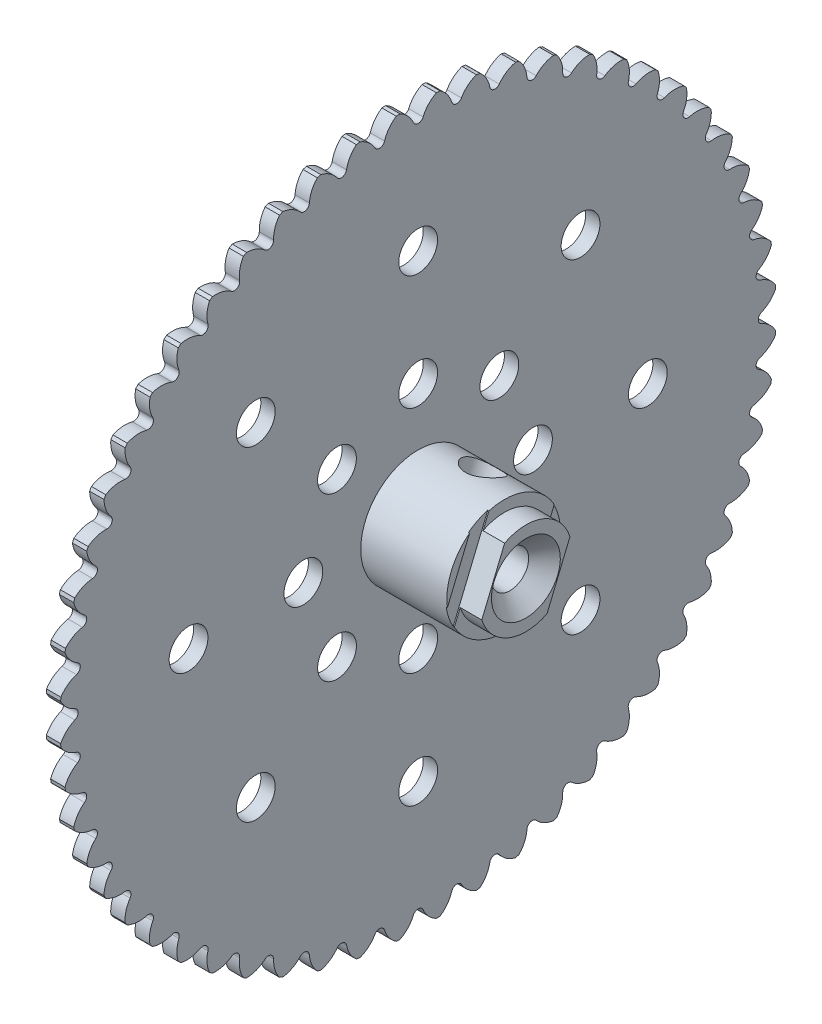
from build123d import *

# Parameters (mm, degrees)
SKETCH1_R           = 39.5986
BOSS_EXTRUDE1_DEPTH = 1.5875
SKETCH2_R           = 2.1463
CUT_EXTRUDE1_DEPTH  = 1.5875
CIRPATTERN1_COUNT   = 8
CUT_EXTRUDE2_DEPTH  = 1.5875
CIRPATTERN2_COUNT   = 56
SKETCH7_R           = 6.35
BOSS_EXTRUDE3_DEPTH = 9.525
BOSS_EXTRUDE4_DEPTH = 2.3876
SKETCH9_R           = 2.0574
CUT_EXTRUDE3_DEPTH  = 14.5001
CUT_EXTRUDE4_DEPTH  = 0.127
SKETCH12_W          = 1.984375
SKETCH12_H          = 12.7


with BuildPart() as part:
    # Sketch1 → Boss-Extrude1 (new body)
    with BuildSketch(Plane(origin=(0, 0, 0), x_dir=(0, 0, -1), z_dir=(1, 0, 0))):
        Circle(SKETCH1_R)
    extrude(amount=BOSS_EXTRUDE1_DEPTH)

    # Sketch2 → Cut-Extrude1 (cut)
    with BuildSketch(Plane(origin=(1.5875, 0, 0), x_dir=(0, 0, -1), z_dir=(1, 0, 0))):
        with Locations((0, 12.7)):
            Circle(SKETCH2_R)
        with Locations((0, 25.4)):
            Circle(SKETCH2_R)
    cut_extrude1 = extrude(amount=-CUT_EXTRUDE1_DEPTH, mode=Mode.SUBTRACT)

    # CirPattern1: Cut-Extrude1 ×8 about axis
    cirpattern1_axis = Axis((0, 0, 0), (1, 0, 0))
    for i in range(1, CIRPATTERN1_COUNT):
        add(cut_extrude1.rotate(cirpattern1_axis, i * 360 / CIRPATTERN1_COUNT), mode=Mode.SUBTRACT)

    # Sketch4 → Cut-Extrude2 (cut)
    with BuildSketch(Plane(origin=(1.5875, 0, 0), x_dir=(0, 0, -1), z_dir=(1, 0, 0))):
        with BuildLine():
            ThreePointArc((2.01740165, 39.547177049), (0, 39.5986), (-2.01740165, 39.547177049))
            ThreePointArc((-2.01740165, 39.547177049), (-1.138604793, 38.888877086), (-0.536592031, 37.970605125))
            ThreePointArc((-0.536592031, 37.970605125), (0, 37.6174), (0.536592031, 37.970605125))
            ThreePointArc((0.536592031, 37.970605125), (1.138604793, 38.888877086), (2.01740165, 39.547177049))
        make_face()
    cut_extrude2 = extrude(amount=-CUT_EXTRUDE2_DEPTH, mode=Mode.SUBTRACT)

    # CirPattern2: Cut-Extrude2 ×56 about axis
    cirpattern2_axis = Axis((0, 0, 0), (1, 0, 0))
    for i in range(1, CIRPATTERN2_COUNT):
        add(cut_extrude2.rotate(cirpattern2_axis, i * 360 / CIRPATTERN2_COUNT), mode=Mode.SUBTRACT)

    # Sketch7 → Boss-Extrude3 (add)
    with BuildSketch(Plane(origin=(1.5875, 0, 0), x_dir=(0, 0, -1), z_dir=(1, 0, 0))):
        Circle(SKETCH7_R)
    extrude(amount=BOSS_EXTRUDE3_DEPTH)

    # Sketch8 → Boss-Extrude4 (add)
    with BuildSketch(Plane(origin=(11.1125, 0, 0), x_dir=(0, 0, -1), z_dir=(1, 0, 0))):
        with BuildLine():
            Line((-4.876953722, -1.552504431), (-2.350740637, 4.546313459))
            ThreePointArc((-2.350740637, 4.546313459), (1.958612075, 4.728507835), (4.876953722, 1.552504431))
            Line((4.876953722, 1.552504431), (2.350740637, -4.546313459))
            ThreePointArc((2.350740637, -4.546313459), (-1.958612075, -4.728507835), (-4.876953722, -1.552504431))
        make_face()
    extrude(amount=BOSS_EXTRUDE4_DEPTH)

    # Sketch9 → Cut-Extrude3 (cut, through all)
    with BuildSketch(Plane(origin=(13.5001, 0, 0), x_dir=(0, 0, -1), z_dir=(1, 0, 0))):
        Circle(SKETCH9_R)
    extrude(amount=-CUT_EXTRUDE3_DEPTH, mode=Mode.SUBTRACT)

    # Sketch10 → Cut-Extrude4 (cut)
    with BuildSketch(Plane(origin=(11.1125, 0, 0), x_dir=(0, 0, -1), z_dir=(1, 0, 0))):
        with BuildLine():
            Line((-5.528101678, -3.124514657), (-1.699592681, 6.118323685))
            ThreePointArc((-1.699592681, 6.118323685), (-2.823102406, 5.687933966), (-3.845267539, 5.053357058))
            Line((-3.845267539, 5.053357058), (-6.292277796, -0.854248291))
            ThreePointArc((-6.292277796, -0.854248291), (-6.018211534, -2.025741823), (-5.528101678, -3.124514657))
        make_face()
        with BuildLine():
            Line((3.845267539, -5.053357058), (6.292277796, 0.854248291))
            ThreePointArc((6.292277796, 0.854248291), (6.018211534, 2.025741823), (5.528101678, 3.124514657))
            Line((5.528101678, 3.124514657), (1.699592681, -6.118323685))
            ThreePointArc((1.699592681, -6.118323685), (2.823102406, -5.687933966), (3.845267539, -5.053357058))
        make_face()
    extrude(amount=-CUT_EXTRUDE4_DEPTH, mode=Mode.SUBTRACT)

    # Sketch11 one side → Cut-Revolve4 (revolve, cut)
    with BuildSketch(Plane.XY):
        Polygon((9.6901, 0), (13.5001, -3.81), (13.5001, 0), align=None)
    revolve(axis=Axis((13.5001, 0, 0), (-1, 0, 0)), mode=Mode.SUBTRACT)

    # Sketch12 → Cut-Revolve5 (revolve, cut)
    with BuildSketch(Plane(origin=(0, 0, 0), x_dir=(-1, 0, 0), z_dir=(0, -0.382683432, -0.923879533))):
        with Locations((-7.3421875, 0)):
            Rectangle(SKETCH12_W, SKETCH12_H)
    revolve(axis=Axis((6.35, -5.866635031, 2.430039796), (0, 0.923879533, -0.382683432)), mode=Mode.SUBTRACT)


solid = part.part
